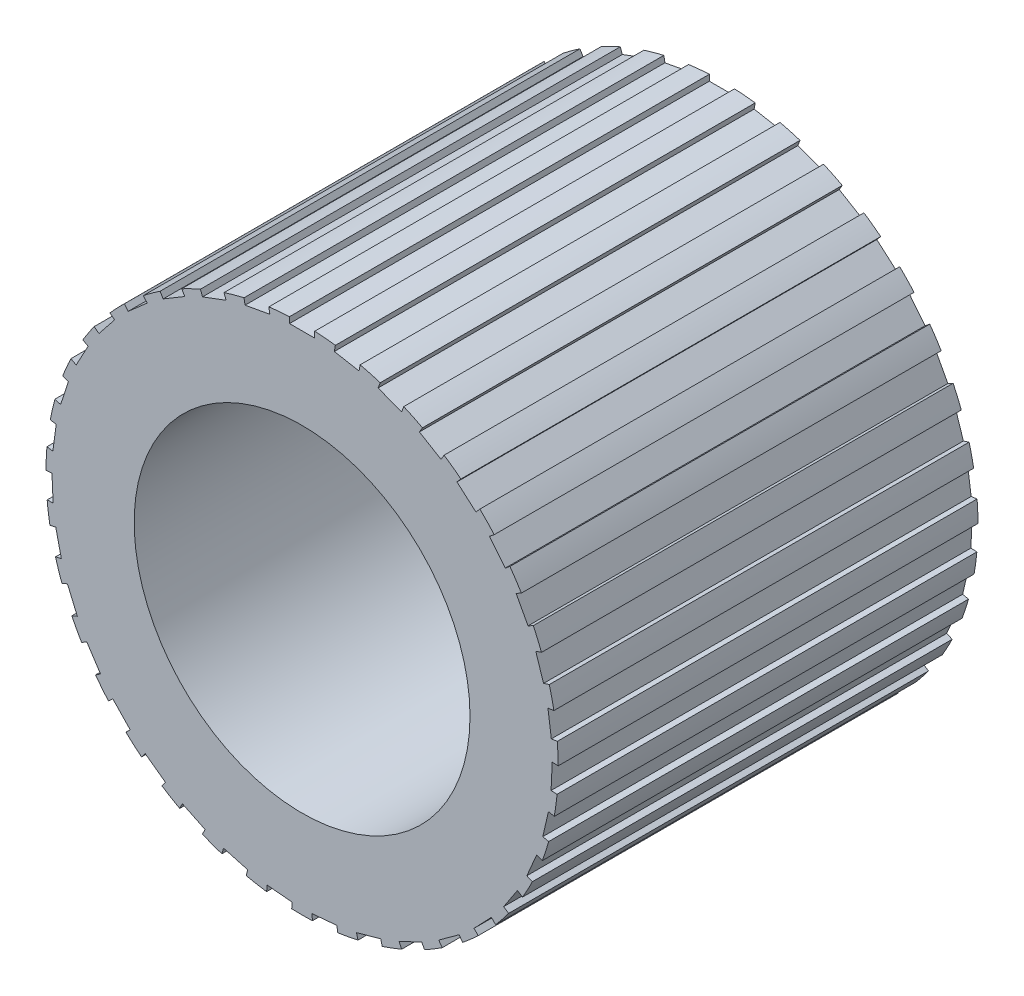
from build123d import *

# Parameters (mm, degrees)
ESQUISSE1_R             = 6.1
ESQUISSE1_R_2           = 4
BOSS_EXTRU_1_DEPTH      = 10
ESQUISSE4_W             = 0.6
ESQUISSE4_H             = 0.3
ENL_V_MAT_EXTRU_3_DEPTH = 10


with BuildPart() as part:
    # Esquisse1 → Boss.-Extru.1 (new body)
    with BuildSketch(Plane.XY):
        Circle(ESQUISSE1_R)
        Circle(ESQUISSE1_R_2, mode=Mode.SUBTRACT)
    extrude(amount=BOSS_EXTRU_1_DEPTH)

    # Esquisse4 → Enlèv. mat.-Extru.3 (cut)
    with BuildSketch(Plane.XY.offset(10)):
        Polygon((0.767234647, 5.907948121), (0.820801716, 6.203126997), (1.411159469, 6.09599286), (1.357592401, 5.800813984), align=None)
        with Locations((0, 6.1)):
            Rectangle(ESQUISSE4_W, ESQUISSE4_H)
        Polygon((1.809809742, 5.676009928), (1.915222189, 5.956880389), (2.476963112, 5.746055494), (2.371550664, 5.465185033), align=None)
        Polygon((2.794216062, 5.261640105), (2.948085846, 5.519174743), (3.463155122, 5.211435177), (3.309285339, 4.953900539), align=None)
        Polygon((3.68881398, 4.678156841), (3.886195597, 4.90407828), (4.338038477, 4.509315045), (4.140656859, 4.283393605), align=None)
        Polygon((4.46485038, 3.944313766), (4.699399825, 4.131360706), (5.073493706, 3.662261817), (4.838944261, 3.475214876), align=None)
        Polygon((5.097382816, 3.083697201), (5.361561475, 3.2258578), (5.645882673, 2.697500481), (5.381704013, 2.555339882), align=None)
        Polygon((5.566081174, 2.123968071), (5.851398129, 2.21667317), (6.036808325, 1.64603926), (5.75149137, 1.553334162), align=None)
        Polygon((5.855881103, 1.09597286), (6.153166031, 1.13624284), (6.233705991, 0.541672983), (5.936421062, 0.501403003), align=None)
        Polygon((5.957468195, 0.032752179), (6.257166115, 0.01929273), (6.230247217, -0.58010311), (5.930549297, -0.566643661), align=None)
        Polygon((5.867577358, -1.031521183), (6.160055731, -1.098277464), (6.026543171, -1.683234211), (5.734064797, -1.616477931), align=None)
        Polygon((5.589097756, -2.062640607), (5.864956088, -2.180548116), (5.629141069, -2.73226478), (5.353282737, -2.61435727), align=None)
        Polygon((5.130979954, -3.027465064), (5.38135193, -3.192734158), (5.050813741, -3.69347811), (4.800441765, -3.528209016), align=None)
        Polygon((4.507948234, -3.894984302), (4.724786694, -4.102303097), (4.310149104, -4.535980015), (4.093310645, -4.328661221), align=None)
        Polygon((3.740027349, -4.637315541), (3.916362925, -4.880020639), (3.430952729, -5.232691791), (3.254617153, -4.989986692), align=None)
        Polygon((2.851898908, -5.230599642), (2.98206403, -5.500890303), (2.441482709, -5.761220546), (2.311317587, -5.490929886), align=None)
        Polygon((1.872108089, -5.655767967), (1.951919143, -5.944956826), (1.373541427, -6.104578933), (1.293730373, -5.815390075), align=None)
        Polygon((0.832146176, -5.899155257), (0.859037969, -6.197947545), (0.261453392, -6.25173113), (0.2345616, -5.952938842), align=None)
        Polygon((-0.2345616, -5.952938842), (-0.261453392, -6.25173113), (-0.859037969, -6.197947545), (-0.832146176, -5.899155257), align=None)
        Polygon((-1.293730373, -5.815390075), (-1.373541427, -6.104578933), (-1.951919143, -5.944956826), (-1.872108089, -5.655767967), align=None)
        Polygon((-2.311317587, -5.490929886), (-2.441482709, -5.761220546), (-2.98206403, -5.500890303), (-2.851898908, -5.230599642), align=None)
        Polygon((-3.254617153, -4.989986692), (-3.430952729, -5.232691791), (-3.916362925, -4.880020639), (-3.740027349, -4.637315541), align=None)
        Polygon((-4.093310645, -4.328661221), (-4.310149104, -4.535980015), (-4.724786694, -4.102303097), (-4.507948234, -3.894984302), align=None)
        Polygon((-4.800441765, -3.528209016), (-5.050813741, -3.69347811), (-5.38135193, -3.192734158), (-5.130979954, -3.027465064), align=None)
        Polygon((-5.353282737, -2.61435727), (-5.629141069, -2.73226478), (-5.864956088, -2.180548116), (-5.589097756, -2.062640607), align=None)
        Polygon((-5.734064797, -1.616477931), (-6.026543171, -1.683234211), (-6.160055731, -1.098277464), (-5.867577358, -1.031521183), align=None)
        Polygon((-5.930549297, -0.566643661), (-6.230247217, -0.58010311), (-6.257166115, 0.01929273), (-5.957468195, 0.032752179), align=None)
        Polygon((-5.936421062, 0.501403003), (-6.233705991, 0.541672983), (-6.153166031, 1.13624284), (-5.855881103, 1.09597286), align=None)
        Polygon((-5.75149137, 1.553334162), (-6.036808325, 1.64603926), (-5.851398129, 2.21667317), (-5.566081174, 2.123968071), align=None)
        Polygon((-5.381704013, 2.555339882), (-5.645882673, 2.697500481), (-5.361561475, 3.2258578), (-5.097382816, 3.083697201), align=None)
        Polygon((-4.838944261, 3.475214876), (-5.073493706, 3.662261817), (-4.699399825, 4.131360706), (-4.46485038, 3.944313766), align=None)
        Polygon((-4.140656859, 4.283393605), (-4.338038477, 4.509315045), (-3.886195597, 4.90407828), (-3.68881398, 4.678156841), align=None)
        Polygon((-3.309285339, 4.953900539), (-3.463155122, 5.211435177), (-2.948085846, 5.519174743), (-2.794216062, 5.261640105), align=None)
        Polygon((-2.371550664, 5.465185033), (-2.476963112, 5.746055494), (-1.915222189, 5.956880389), (-1.809809742, 5.676009928), align=None)
        Polygon((-1.357592401, 5.800813984), (-1.411159469, 6.09599286), (-0.820801716, 6.203126997), (-0.767234647, 5.907948121), align=None)
    extrude(amount=-ENL_V_MAT_EXTRU_3_DEPTH, mode=Mode.SUBTRACT)


solid = part.part
